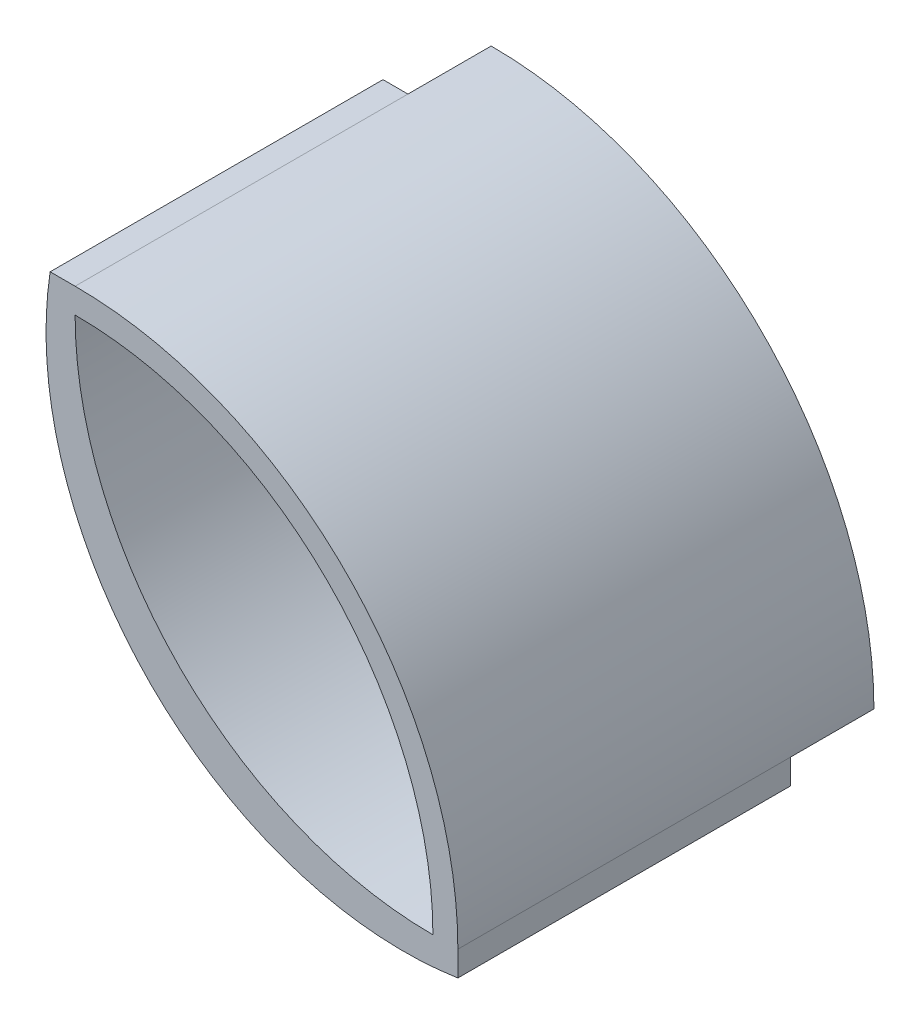
from build123d import *

# Parameters (mm, degrees)
BOSS_EXTRUDE1_DEPTH = 10
BOSS_EXTRUDE2_DEPTH = 40
BOSS_EXTRUDE3_DEPTH = 40


with BuildPart() as part:
    # Sketch1 → Boss-Extrude1 (new body)
    with BuildSketch(Plane.XY):
        with BuildLine():
            Line((0, 46), (0, 43))
            ThreePointArc((0, 43), (30.405591591, 30.405591591), (43, 0))
            Line((43, 0), (46, 0))
            ThreePointArc((46, 0), (32.526911935, 32.526911935), (0, 46))
        make_face()
    extrude(amount=BOSS_EXTRUDE1_DEPTH)



with BuildPart() as body_2:
    # Sketch3 → Boss-Extrude2 (new body)
    with BuildSketch(Plane.XY.offset(10)):
        with BuildLine():
            Line((0, 46), (-3, 46))
            ThreePointArc((-3, 46), (9.101351514, 9.101351514), (46, -3))
            Line((46, -3), (46, 0))
            Line((46, 0), (43, 0))
            ThreePointArc((43, 0), (12.594408409, 12.594408409), (0, 43))
            Line((0, 43), (0, 46))
        make_face()
    extrude(amount=BOSS_EXTRUDE2_DEPTH)


with BuildPart() as part_1:
    add(part.part)

    add(body_2.part)  # Boss-Extrude3 merges body 2
    # Sketch4 → Boss-Extrude3 (add)
    with BuildSketch(Plane.XY.offset(10)):
        with BuildLine():
            Line((0, 46), (0, 43))
            ThreePointArc((0, 43), (30.405591591, 30.405591591), (43, 0))
            Line((43, 0), (46, 0))
            ThreePointArc((46, 0), (32.526911935, 32.526911935), (0, 46))
        make_face()
    extrude(amount=BOSS_EXTRUDE3_DEPTH)


solid = part_1.part
